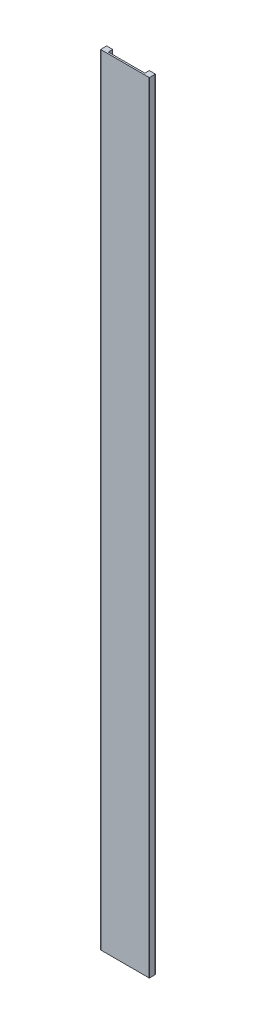
from build123d import *

# Parameters (mm, degrees)
BOSS_EXTRUDE1_DEPTH = 1219.2
FILLET1_R           = 0.381


with BuildPart() as part:
    # Sketch2 → Boss-Extrude1 (new body)
    with BuildSketch(Plane(origin=(0, 0, 0), x_dir=(1, 0, 0), z_dir=(0, 1, 0))):
        Polygon((-38.1, 0), (38.1, 0), (38.1, 9.525), (28.575, 9.525), (28.575, 2.54), (-28.575, 2.54), (-28.575, 9.525), (-38.1, 9.525), align=None)
    extrude(amount=BOSS_EXTRUDE1_DEPTH)

    # Fillet1
    fillet1_edges = [part.edges().sort_by_distance(p)[0] for p in [
        (38.1, 609.6, 0),
        (-38.1, 609.6, 0),
        (-38.1, 609.6, -9.525),
        (-28.575, 609.6, -9.525),
        (-28.575, 609.6, -2.54),
        (28.575, 609.6, -2.54),
        (28.575, 609.6, -9.525),
        (38.1, 609.6, -9.525),
    ]]
    fillet(fillet1_edges, radius=FILLET1_R)


solid = part.part
